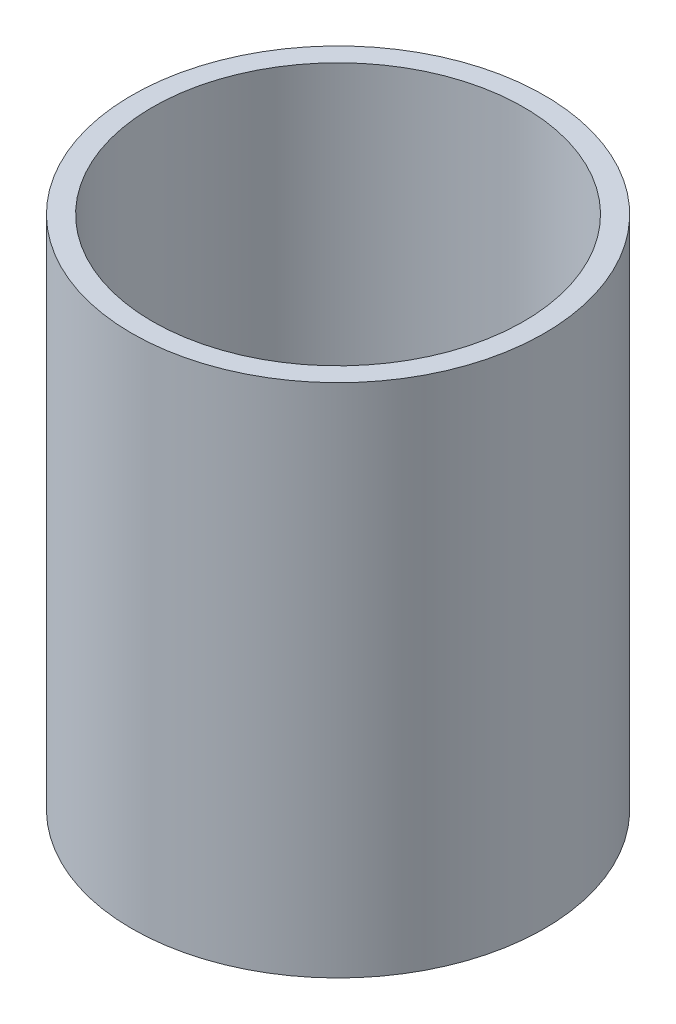
from build123d import *

# Parameters (mm, degrees)
SKETCH1_R           = 20
BOSS_EXTRUDE1_DEPTH = 50
SHELL3_T            = -2
CUT_EXTRUDE1_DEPTH  = 50


with BuildPart() as part:
    # Sketch1 → Boss-Extrude1 (new body)
    with BuildSketch(Plane(origin=(0, 0, 0), x_dir=(1, 0, 0), z_dir=(0, 1, 0))):
        with Locations(Location((0, 0, 0), (0, 0, 270))):
            Circle(SKETCH1_R)
    extrude(amount=BOSS_EXTRUDE1_DEPTH)

    # Shell3
    shell3_openings = [part.faces().sort_by_distance(p)[0] for p in [
        (0, 50, 0),
    ]]
    offset(amount=SHELL3_T, openings=shell3_openings, kind=Kind.INTERSECTION)

    # Sketch2 → Cut-Extrude1 (cut)
    with BuildSketch(Plane(origin=(0, 2, 0), x_dir=(1, 0, 0), z_dir=(0, 1, 0))):
        with BuildLine():
            Line((-1, -16.970562748), (-1, 16.970562748))
            ThreePointArc((-1, 16.970562748), (-17, 0), (-1, -16.970562748))
        make_face()
        with BuildLine():
            ThreePointArc((17, 0), (12.369316877, 11.66190379), (1, 16.970562748))
            Line((1, 16.970562748), (1, -16.970562748))
            ThreePointArc((1, -16.970562748), (12.369316877, -11.66190379), (17, 0))
        make_face()
    extrude(amount=-CUT_EXTRUDE1_DEPTH, mode=Mode.SUBTRACT)


solid = part.part
